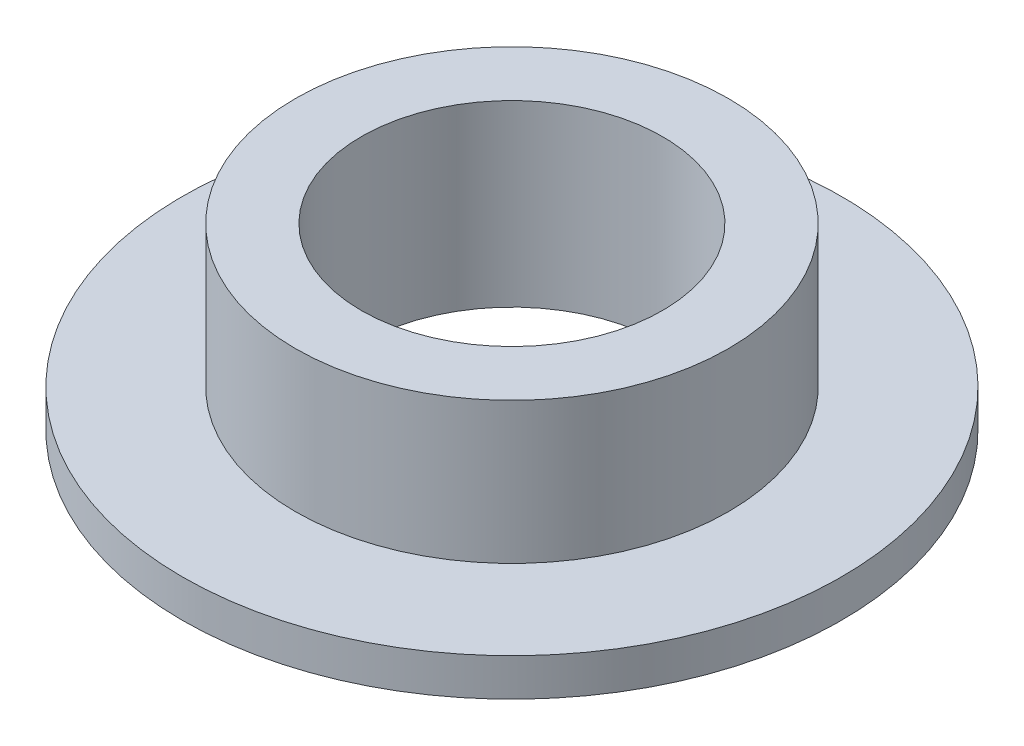
from build123d import *

# Parameters (mm, degrees)
SKETCH1_R           = 3.5
BOSS_EXTRUDE1_DEPTH = 0.4
SKETCH2_R           = 2.3
BOSS_EXTRUDE2_DEPTH = 1.5
SKETCH3_R           = 1.6
CUT_EXTRUDE1_DEPTH  = 16


with BuildPart() as part:
    # Sketch1 → Boss-Extrude1 (new body)
    with BuildSketch(Plane(origin=(0, 0, 0), x_dir=(1, 0, 0), z_dir=(0, 1, 0))):
        Circle(SKETCH1_R)
    extrude(amount=BOSS_EXTRUDE1_DEPTH)

    # Sketch2 → Boss-Extrude2 (add)
    with BuildSketch(Plane(origin=(0, 0.4, 0), x_dir=(1, 0, 0), z_dir=(0, 1, 0))):
        Circle(SKETCH2_R)
    extrude(amount=BOSS_EXTRUDE2_DEPTH)

    # Sketch3 → Cut-Extrude1 (cut)
    with BuildSketch(Plane(origin=(0, 1.9, 0), x_dir=(1, 0, 0), z_dir=(0, 1, 0))):
        Circle(SKETCH3_R)
    extrude(amount=-CUT_EXTRUDE1_DEPTH, mode=Mode.SUBTRACT)


solid = part.part
